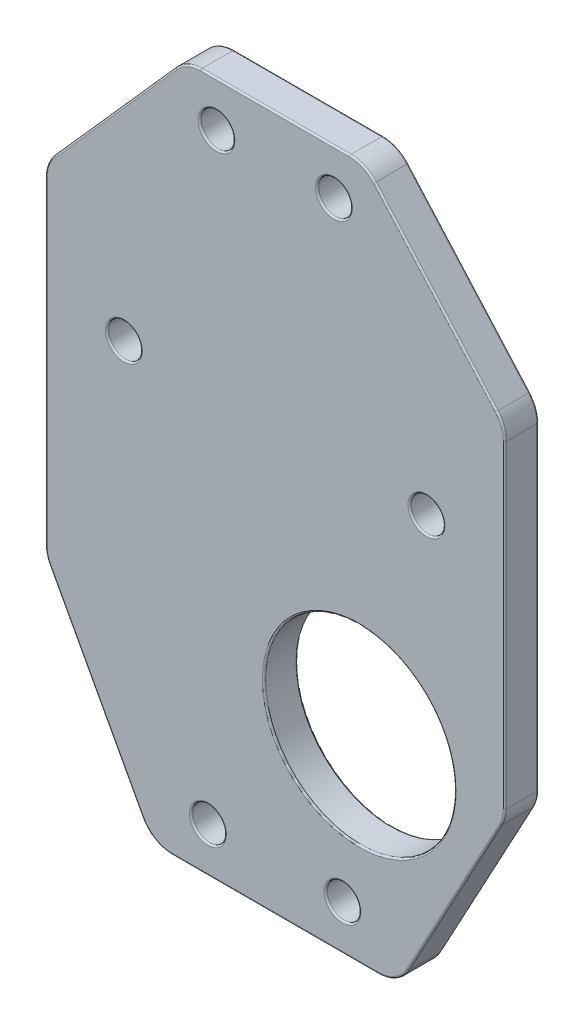
from build123d import *

# Parameters (mm, degrees)
SKETCH1_R           = 1.5
SKETCH1_R_2         = 8.5
BOSS_EXTRUDE1_DEPTH = 3
FILLET1_R           = 3
FILLET2_R           = 0.15


with BuildPart() as part:
    # Sketch1 → Boss-Extrude1 (new body)
    with BuildSketch(Plane.XY):
        Polygon((7.989824602, 62), (-7.989824602, 62), (-20.5, 47.899715907), (-20.5, 17.599715907), (-11, 0), (0, 0), (11, 0), (20.5, 17.599715907), (20.5, 47.899715907), align=None)
        with Locations((-6, 4)):
            Circle(SKETCH1_R, mode=Mode.SUBTRACT)
        with Locations((-13.5, 37.599715907)):
            Circle(SKETCH1_R, mode=Mode.SUBTRACT)
        with Locations((-5.239824602, 58)):
            Circle(SKETCH1_R, mode=Mode.SUBTRACT)
        with Locations((5.239824602, 58)):
            Circle(SKETCH1_R, mode=Mode.SUBTRACT)
        with Locations((13.5, 37.599715907)):
            Circle(SKETCH1_R, mode=Mode.SUBTRACT)
        with Locations((6, 4)):
            Circle(SKETCH1_R, mode=Mode.SUBTRACT)
        with Locations((7.5, 17.599715907)):
            Circle(SKETCH1_R_2, mode=Mode.SUBTRACT)
    extrude(amount=BOSS_EXTRUDE1_DEPTH)

    # Fillet1
    fillet1_edges = [part.edges().sort_by_distance(p)[0] for p in [
        (-11, 0, 1.5),
        (-20.5, 17.599715907, 1.5),
        (-20.5, 47.899715907, 1.5),
        (-7.989824602, 62, 1.5),
        (7.989824602, 62, 1.5),
        (20.5, 47.899715907, 1.5),
        (20.5, 17.599715907, 1.5),
        (11, 0, 1.5),
    ]]
    fillet(fillet1_edges, radius=FILLET1_R)

    # Fillet2
    fillet2_edges = [part.edges().sort_by_distance(p)[0] for p in [
        (-7.5, 4, 0),
        (-7.5, 4, 3),
        (-15, 37.599715907, 0),
        (-15, 37.599715907, 3),
        (-6.739824602, 58, 0),
        (-6.739824602, 58, 3),
        (3.739824602, 58, 0),
        (3.739824602, 58, 3),
        (12, 37.599715907, 0),
        (12, 37.599715907, 3),
        (4.5, 4, 0),
        (4.5, 4, 3),
        (-1, 17.599715907, 0),
        (-1, 17.599715907, 3),
        (0, 0, 0),
        (0, 0, 3),
        (15.995056577, 9.253850179, 0),
        (-15.995056577, 9.253850179, 0),
        (-20.5, 32.559205816, 0),
        (-14.314553508, 54.871364985, 0),
        (0, 62, 0),
        (14.314553508, 54.871364985, 0),
        (20.5, 32.559205816, 0),
        (20.408596926, 17.622809943, 0),
        (10.747240997, 0.423665394, 0),
        (20.304659617, 47.825551373, 0),
        (7.871191108, 61.736149488, 0),
        (-7.871191108, 61.736149488, 0),
        (-20.304659617, 47.825551373, 0),
        (-20.408596926, 17.622809943, 0),
        (-10.747240997, 0.423665394, 0),
        (-15.995056577, 9.253850179, 3),
        (15.995056577, 9.253850179, 3),
        (20.5, 32.559205816, 3),
        (14.314553508, 54.871364985, 3),
        (0, 62, 3),
        (-14.314553508, 54.871364985, 3),
        (-20.5, 32.559205816, 3),
        (20.408596926, 17.622809943, 3),
        (10.747240997, 0.423665394, 3),
        (20.304659617, 47.825551373, 3),
        (7.871191108, 61.736149488, 3),
        (-7.871191108, 61.736149488, 3),
        (-20.304659617, 47.825551373, 3),
        (-20.408596926, 17.622809943, 3),
        (-10.747240997, 0.423665394, 3),
    ]]
    fillet(fillet2_edges, radius=FILLET2_R)


solid = part.part
